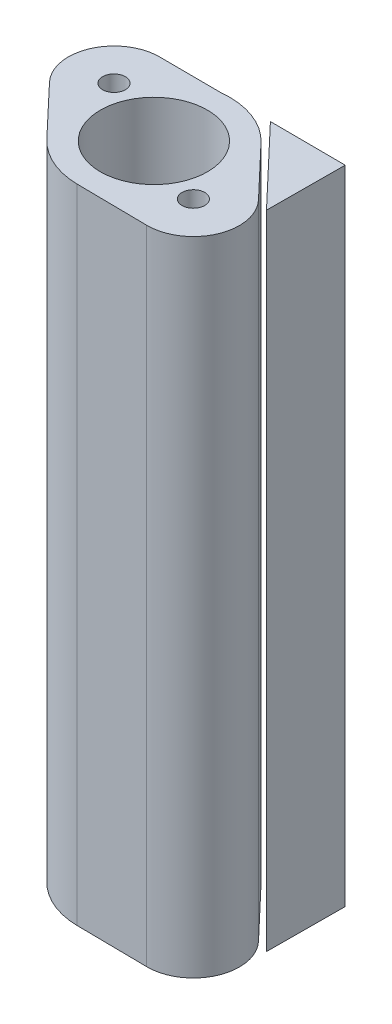
from build123d import *

# Parameters (mm, degrees)
CROQUIS1_R                            = 3.583990311
CROQUIS1_R_2                          = 0.761712319
MAIN_DEPTH                            = 50
SOPORTE_IMPRESI_N_REACH               = 12.612
SOPORTE_IMPRESI_N_OFFSET_FROM_SURFACE = 0.4
CROQUIS9_W                            = 5.162810259
CROQUIS9_H                            = 50
CROQUIS9_W_2                          = 3.172851398
CROQUIS9_H_2                          = 5.265929043
CROQUIS9_H_3                          = 5.56879997
CROQUIS9_H_4                          = 6.378318597
CROQUIS9_H_5                          = 7.695217182
CROQUIS9_H_6                          = 7.257188423
CROQUIS9_H_7                          = 7.861259403
CROQUIS10_W                           = 16.930665583
CROQUIS10_H                           = 7.998462294
AJUSTE_DE_LONGITUD_DEPTH              = 20


with BuildPart() as part:
    # Croquis1 → Main (new body)
    with BuildSketch(Plane(origin=(0, 0, 0), x_dir=(1, 0, 0), z_dir=(0, 1, 0))):
        with BuildLine():
            Line((4.50248526, -6.429915097), (7.747476145, -9.845240308))
            ThreePointArc((7.747476145, -9.845240308), (8.338348215, -13.204009355), (5.473726293, -15.054522947))
            Line((5.473726293, -15.054522947), (0.762978959, -14.997324233))
            ThreePointArc((0.762978959, -14.997324233), (-1.208594731, -14.57247254), (-2.858853831, -13.413056012))
            Line((-2.858853831, -13.413056012), (-6.078991771, -10.013141592))
            ThreePointArc((-6.078991771, -10.013141592), (-6.648174073, -6.662123841), (-3.766616226, -4.85937238))
            Line((-3.766616226, -4.85937238), (0.277312206, -4.880694454))
            ThreePointArc((0.277312206, -4.880694454), (2.571074261, -5.161186678), (4.50248526, -6.429915097))
        make_face()
        with Locations((0.824575354, -9.924394652)):
            Circle(CROQUIS1_R, mode=Mode.SUBTRACT)
        with Locations((-3.861167301, -7.912588509)):
            Circle(CROQUIS1_R_2, mode=Mode.SUBTRACT)
        with Locations((5.511179043, -11.970005379)):
            Circle(CROQUIS1_R_2, mode=Mode.SUBTRACT)
    extrude(amount=-MAIN_DEPTH)


with BuildPart() as body_2:

    # Soporte impresión: up to this face of the body (flat: up to its plane, moved by the offset)
    soporte_impresi_n_end = Plane(part.part.faces().sort_by_distance((6.124980703, -25, 8.137577703))[0]).offset(SOPORTE_IMPRESI_N_OFFSET_FROM_SURFACE)
    # Croquis9 → Soporte impresión (new body, up to the picked face)
    with BuildSketch(Plane(origin=(-0.025725594, 0, 4.879096653), x_dir=(-0.9999861, 0, -0.005272541), z_dir=(0.005272541, 0, -0.9999861)), mode=Mode.PRIVATE) as soporte_impresi_n_sk1:
        with Locations((-6.077554591, -25)):
            Rectangle(CROQUIS9_W, CROQUIS9_H)
        with Locations((-6.072534021, -46.367035479)):
            Rectangle(CROQUIS9_W_2, CROQUIS9_H_2, mode=Mode.SUBTRACT)
        with Locations((-6.072534021, -3.784399985)):
            Rectangle(CROQUIS9_W_2, CROQUIS9_H_3, mode=Mode.SUBTRACT)
        with Locations((-6.072534021, -11.440621391)):
            Rectangle(CROQUIS9_W_2, CROQUIS9_H_4, mode=Mode.SUBTRACT)
        with Locations((-6.072534021, -19.794287865)):
            Rectangle(CROQUIS9_W_2, CROQUIS9_H_5, mode=Mode.SUBTRACT)
        with Locations((-6.072534021, -28.907216676)):
            Rectangle(CROQUIS9_W_2, CROQUIS9_H_6, mode=Mode.SUBTRACT)
        with Locations((-6.072534021, -37.757738206)):
            Rectangle(CROQUIS9_W_2, CROQUIS9_H_7, mode=Mode.SUBTRACT)
    soporte_impresi_n_tool1 = split(extrude(soporte_impresi_n_sk1.sketch, amount=-SOPORTE_IMPRESI_N_REACH, mode=Mode.PRIVATE), bisect_by=soporte_impresi_n_end, keep=Keep.BOTH, mode=Mode.PRIVATE)
    add(soporte_impresi_n_tool1.solids().sort_by_distance((6.056606, -25.085307, 4.911166))[0])


with BuildPart() as ajuste_de_longitud_tool:
    # Croquis10 → Ajuste de longitud (new body)
    with BuildSketch(Plane.XY):
        with Locations((0.809895843, -3.000768853)):
            Rectangle(CROQUIS10_W, CROQUIS10_H)
    extrude(amount=AJUSTE_DE_LONGITUD_DEPTH)


with BuildPart() as part_1:
    add(part.part)

    # Ajuste de longitud: cut by ajuste_de_longitud_tool
    add(ajuste_de_longitud_tool.part, mode=Mode.SUBTRACT)


with BuildPart() as body_2_1:
    add(body_2.part)

    # Ajuste de longitud: cut by ajuste_de_longitud_tool
    add(ajuste_de_longitud_tool.part, mode=Mode.SUBTRACT)


solid = Compound([part_1.part, body_2_1.part])
